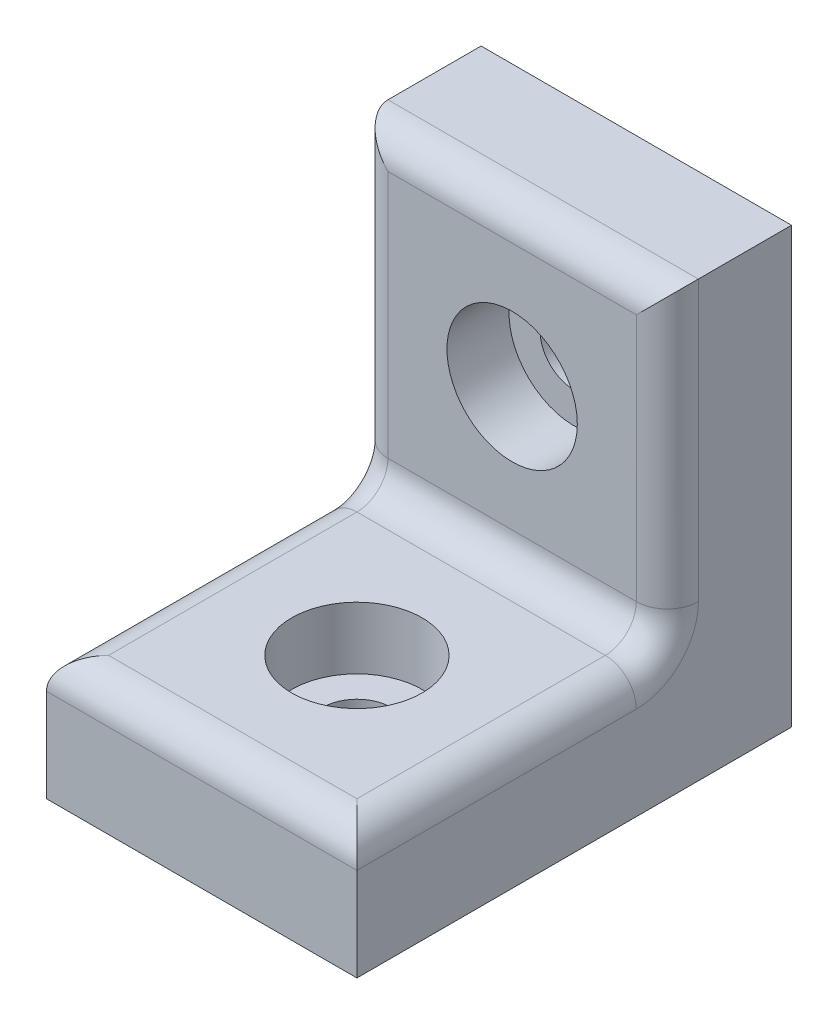
from build123d import *

# Parameters (mm, degrees)
ESQUISSE1_W             = 10
ESQUISSE1_H             = 14
BOSS_EXTRU_1_DEPTH      = 4
ESQUISSE2_W             = 10
ESQUISSE2_H             = 4
BOSS_EXTRU_2_DEPTH      = 10
ESQUISSE3_R             = 1.1
ENL_V_MAT_EXTRU_1_DEPTH = 5
CONG_1_R                = 1
ESQUISSE4_R             = 1.1
ENL_V_MAT_EXTRU_2_DEPTH = 5
ESQUISSE5_R             = 2.1
ENL_V_MAT_EXTRU_3_DEPTH = 2
ESQUISSE6_R             = 2.1
ENL_V_MAT_EXTRU_4_DEPTH = 2


with BuildPart() as part:
    # Esquisse1 → Boss.-Extru.1 (new body)
    with BuildSketch(Plane.XY):
        with Locations((0, 7)):
            Rectangle(ESQUISSE1_W, ESQUISSE1_H)
    extrude(amount=BOSS_EXTRU_1_DEPTH)

    # Esquisse2 → Boss.-Extru.2 (add)
    with BuildSketch(Plane.XY.offset(4)):
        with Locations((0, 2)):
            Rectangle(ESQUISSE2_W, ESQUISSE2_H)
    extrude(amount=BOSS_EXTRU_2_DEPTH)

    # Esquisse3 → Enlèv. mat.-Extru.1 (cut, through all)
    with BuildSketch(Plane.XY.offset(4)):
        with Locations((0, 9)):
            Circle(ESQUISSE3_R)
    extrude(amount=-ENL_V_MAT_EXTRU_1_DEPTH, mode=Mode.SUBTRACT)

    # Congé1
    cong_1_edges = [part.edges().sort_by_distance(p)[0] for p in [
        (5, 9, 4),
        (-5, 4, 9),
        (0, 4, 4),
        (5, 4, 9),
        (0, 14, 4),
        (0, 4, 14),
        (-5, 9, 4),
    ]]
    fillet(cong_1_edges, radius=CONG_1_R)

    # Esquisse4 → Enlèv. mat.-Extru.2 (cut, through all)
    with BuildSketch(Plane(origin=(0, 4, 0), x_dir=(1, 0, 0), z_dir=(0, 1, 0))):
        with Locations(Location((0, -9, 0), (0, 0, 270))):  # turned: the seam where the file's is
            Circle(ESQUISSE4_R)
    extrude(amount=-ENL_V_MAT_EXTRU_2_DEPTH, mode=Mode.SUBTRACT)

    # Esquisse5 → Enlèv. mat.-Extru.3 (cut)
    with BuildSketch(Plane.XY.offset(4)):
        with Locations((0, 9)):
            Circle(ESQUISSE5_R)
    extrude(amount=-ENL_V_MAT_EXTRU_3_DEPTH, mode=Mode.SUBTRACT)

    # Esquisse6 → Enlèv. mat.-Extru.4 (cut)
    with BuildSketch(Plane(origin=(0, 4, 0), x_dir=(1, 0, 0), z_dir=(0, 1, 0))):
        with Locations(Location((0, -9, 0), (0, 0, 270))):  # turned: the seam where the file's is
            Circle(ESQUISSE6_R)
    extrude(amount=-ENL_V_MAT_EXTRU_4_DEPTH, mode=Mode.SUBTRACT)


solid = part.part
